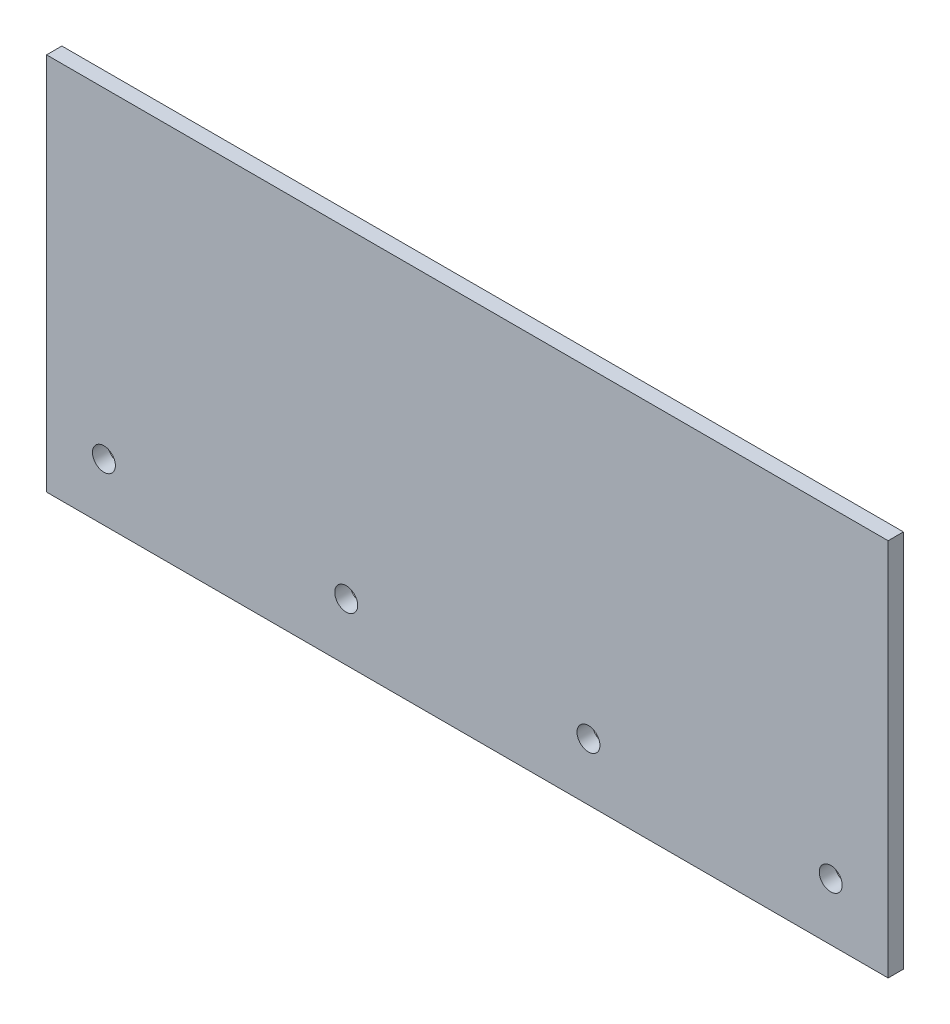
from build123d import *

# Parameters (mm, degrees)
SKICA1_W                = 220
SKICA1_H                = 99
SKICA1_R                = 3
P_IDAT_VYSUNUT_M1_DEPTH = 4


with BuildPart() as part:
    # Skica1 → Přidat vysunutím1 (new body)
    with BuildSketch(Plane.XY):
        with Locations((110, 49.5)):
            Rectangle(SKICA1_W, SKICA1_H)
        with Locations((205, 15)):
            Circle(SKICA1_R, mode=Mode.SUBTRACT)
        with Locations((15, 15)):
            Circle(SKICA1_R, mode=Mode.SUBTRACT)
        with Locations((141.666666667, 15)):
            Circle(SKICA1_R, mode=Mode.SUBTRACT)
        with Locations((78.333333333, 15)):
            Circle(SKICA1_R, mode=Mode.SUBTRACT)
    extrude(amount=P_IDAT_VYSUNUT_M1_DEPTH)


solid = part.part
